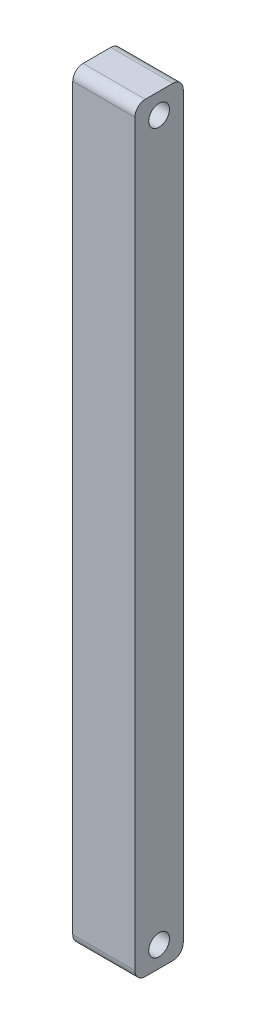
from build123d import *

# Parameters (mm, degrees)
SKETCH1_W           = 9
SKETCH1_H           = 110
BOSS_EXTRUDE2_DEPTH = 7
SKETCH4_R           = 1.5
CUT_EXTRUDE2_DEPTH  = 10
SKETCH6_R           = 1.5
CUT_EXTRUDE4_DEPTH  = 10
FILLET1_R           = 1.5
FILLET2_R           = 1.5


with BuildPart() as part:
    # Sketch1 → Boss-Extrude2 (new body)
    with BuildSketch(Plane.XY):
        with Locations((3.95483871, 54.062211982)):
            Rectangle(SKETCH1_W, SKETCH1_H)
    extrude(amount=BOSS_EXTRUDE2_DEPTH)

    # Sketch4 → Cut-Extrude2 (cut, through all)
    with BuildSketch(Plane(origin=(8.45483871, 0, 0), x_dir=(0, 0, -1), z_dir=(1, 0, 0))):
        with Locations((-3.5, 2.062211982)):
            Circle(SKETCH4_R)
    extrude(amount=-CUT_EXTRUDE2_DEPTH, mode=Mode.SUBTRACT)

    # Sketch6 → Cut-Extrude4 (cut, through all)
    with BuildSketch(Plane(origin=(8.45483871, 0, 0), x_dir=(0, 0, -1), z_dir=(1, 0, 0))):
        with Locations((-3.5, 106.062211982)):
            Circle(SKETCH6_R)
    extrude(amount=-CUT_EXTRUDE4_DEPTH, mode=Mode.SUBTRACT)

    # Fillet1
    fillet1_edges = [part.edges().sort_by_distance(p)[0] for p in [
        (3.95483871, 109.062211982, 7),
        (3.95483871, 109.062211982, 0),
    ]]
    fillet(fillet1_edges, radius=FILLET1_R)

    # Fillet2
    fillet2_edges = [part.edges().sort_by_distance(p)[0] for p in [
        (3.95483871, -0.937788018, 7),
        (3.95483871, -0.937788018, 0),
    ]]
    fillet(fillet2_edges, radius=FILLET2_R)


solid = part.part
